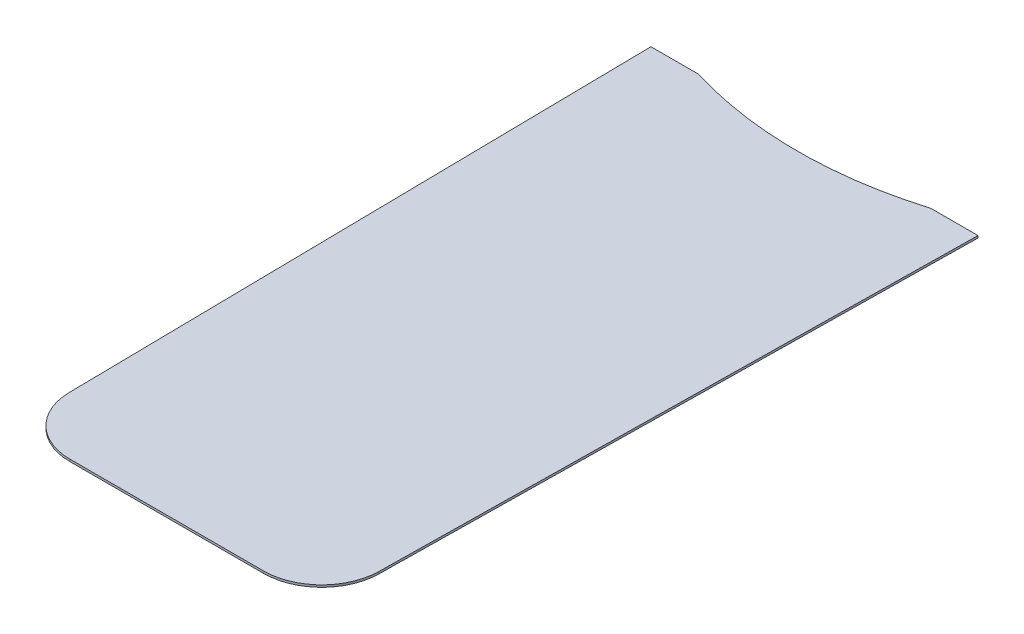
from build123d import *

# Parameters (mm, degrees)
AUFSATZ_LINEAR_AUSTRAGEN1_DEPTH = 0.25
AUFSATZ_LINEAR_AUSTRAGEN2_DEPTH = 0.5


with BuildPart() as part:
    # Skizze1 → Aufsatz-Linear austragen1 (new body, symmetric)
    with BuildSketch(Plane(origin=(0, 0, 0), x_dir=(1, 0, 0), z_dir=(0, 1, 0))):
        with BuildLine():
            Line((-36, 77.25), (-27, 77.25))
            ThreePointArc((-27, 77.25), (0, 73.25), (27, 77.25))
            Line((27, 77.25), (36, 77.25))
            Line((36, 77.25), (36, -59.75))
            ThreePointArc((36, -59.75), (32.045941546, -69.295941546), (22.5, -73.25))
            Line((22.5, -73.25), (-22.5, -73.25))
            ThreePointArc((-22.5, -73.25), (-32.045941546, -69.295941546), (-36, -59.75))
            Line((-36, -59.75), (-36, 77.25))
        make_face()
    extrude(amount=AUFSATZ_LINEAR_AUSTRAGEN1_DEPTH, both=True)

    # Skizze2 → Aufsatz-Linear austragen2 (add)
    with BuildSketch(Plane(origin=(0, 0.25, 0), x_dir=(1, 0, 0), z_dir=(0, 1, 0))):
        with BuildLine():
            Line((-35.998563753, -59.946917797), (-38, 77.25))
            Line((-38, 77.25), (-36, 77.25))
            Line((-36, 77.25), (-36, -59.75))
            ThreePointArc((-36, -59.75), (-35.999640933, -59.848461517), (-35.998563753, -59.946917797))
        make_face()
        with BuildLine():
            Line((36, 77.25), (36, -59.75))
            ThreePointArc((36, -59.75), (35.999640933, -59.848461517), (35.998563753, -59.946917797))
            Line((35.998563753, -59.946917797), (38, 77.25))
            Line((38, 77.25), (36, 77.25))
        make_face()
    extrude(amount=-AUFSATZ_LINEAR_AUSTRAGEN2_DEPTH)


solid = part.part
